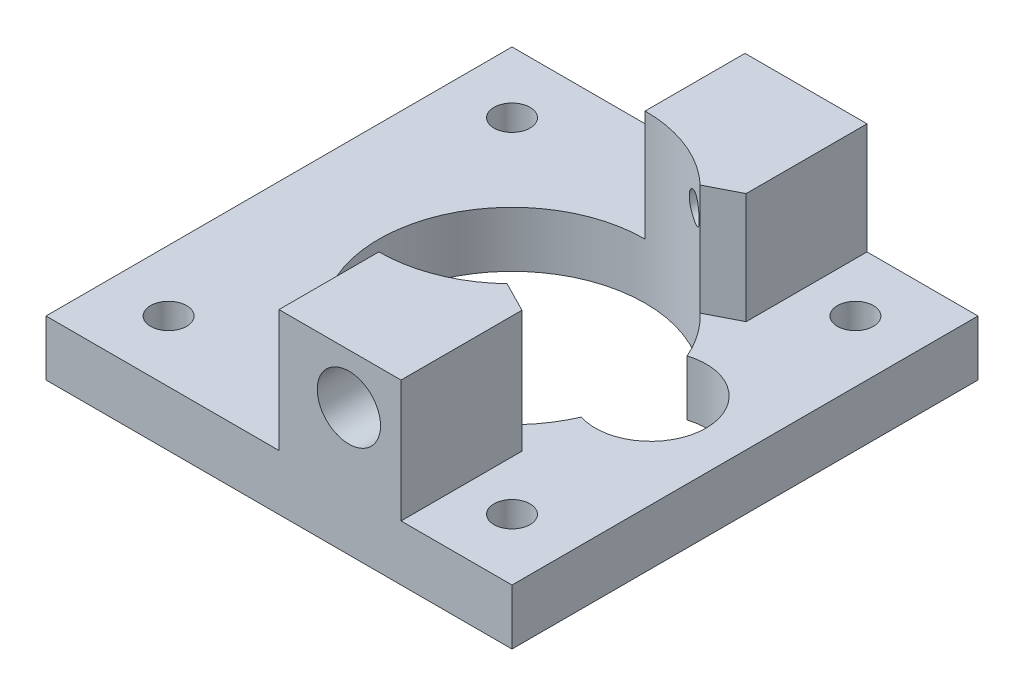
from build123d import *

# Parameters (mm, degrees)
SKETCH1_W           = 42
SKETCH1_H           = 42
SKETCH1_R           = 12
BOSS_EXTRUDE1_DEPTH = 5
SKETCH2_R           = 1.625
CUT_EXTRUDE1_DEPTH  = 8
BOSS_EXTRUDE2_DEPTH = 10
SKETCH4_R           = 1.175
CUT_EXTRUDE2_DEPTH  = 42
SKETCH5_R           = 5
CUT_EXTRUDE3_DEPTH  = 10
SKETCH6_R           = 2.85
CUT_EXTRUDE4_DEPTH  = 5
BOSS_EXTRUDE3_DEPTH = 1


with BuildPart() as part:
    # Sketch1 → Boss-Extrude1 (new body)
    with BuildSketch(Plane(origin=(0, 0, 0), x_dir=(1, 0, 0), z_dir=(0, 1, 0))):
        Rectangle(SKETCH1_W, SKETCH1_H)
        Circle(SKETCH1_R, mode=Mode.SUBTRACT)
    extrude(amount=BOSS_EXTRUDE1_DEPTH)

    # Sketch2 → Cut-Extrude1 (cut)
    with BuildSketch(Plane(origin=(0, 5, 0), x_dir=(1, 0, 0), z_dir=(0, 1, 0))):
        with Locations((-15.475, 15.475)):
            Circle(SKETCH2_R)
        with Locations((15.475, 15.475)):
            Circle(SKETCH2_R)
        with Locations((15.475, -15.475)):
            Circle(SKETCH2_R)
        with Locations((-15.475, -15.475)):
            Circle(SKETCH2_R)
    extrude(amount=-CUT_EXTRUDE1_DEPTH, mode=Mode.SUBTRACT)

    # Sketch3 → Boss-Extrude2 (add)
    with BuildSketch(Plane(origin=(0, 5, 0), x_dir=(1, 0, 0), z_dir=(0, 1, 0))):
        with BuildLine():
            Line((0, 12), (0, 21))
            Line((0, 21), (11, 21))
            Line((11, 21), (11, 10.102949137))
            Line((11, 10.102949137), (8.260404548, 8.704350447))
            ThreePointArc((8.260404548, 8.704350447), (4.446785054, 11.145676412), (0, 12))
        make_face()
        with BuildLine():
            Line((0, -21), (11, -21))
            Line((11, -21), (11, -10.102949137))
            Line((11, -10.102949137), (8.260404548, -8.704350447))
            ThreePointArc((8.260404548, -8.704350447), (4.446785054, -11.145676412), (0, -12))
            Line((0, -12), (0, -21))
        make_face()
    extrude(amount=BOSS_EXTRUDE2_DEPTH)

    # Sketch4 → Cut-Extrude2 (cut)
    with BuildSketch(Plane.XY.offset(21)):
        with Locations((6.3, 11.5)):
            Circle(SKETCH4_R)
    extrude(amount=-CUT_EXTRUDE2_DEPTH, mode=Mode.SUBTRACT)

    # Sketch5 → Cut-Extrude3 (cut)
    with BuildSketch(Plane(origin=(0, 5, 0), x_dir=(1, 0, 0), z_dir=(0, 1, 0))):
        with Locations((12.5, 0)):
            Circle(SKETCH5_R)
    extrude(amount=-CUT_EXTRUDE3_DEPTH, mode=Mode.SUBTRACT)

    # Sketch6 → Cut-Extrude4 (cut)
    with BuildSketch(Plane.XY.offset(21)):
        with Locations((6.3, 11.5)):
            Circle(SKETCH6_R)
    extrude(amount=-CUT_EXTRUDE4_DEPTH, mode=Mode.SUBTRACT)

    # Sketch7 → Boss-Extrude3 (add)
    with BuildSketch(Plane(origin=(0, 15, 0), x_dir=(1, 0, 0), z_dir=(0, 1, 0))):
        with BuildLine():
            Line((0, -21), (11, -21))
            Line((11, -21), (11, -10.102949137))
            Line((11, -10.102949137), (8.260404548, -8.704350447))
            ThreePointArc((8.260404548, -8.704350447), (4.446785054, -11.145676412), (0, -12))
            Line((0, -12), (0, -21))
        make_face()
    extrude(amount=BOSS_EXTRUDE3_DEPTH)


solid = part.part
